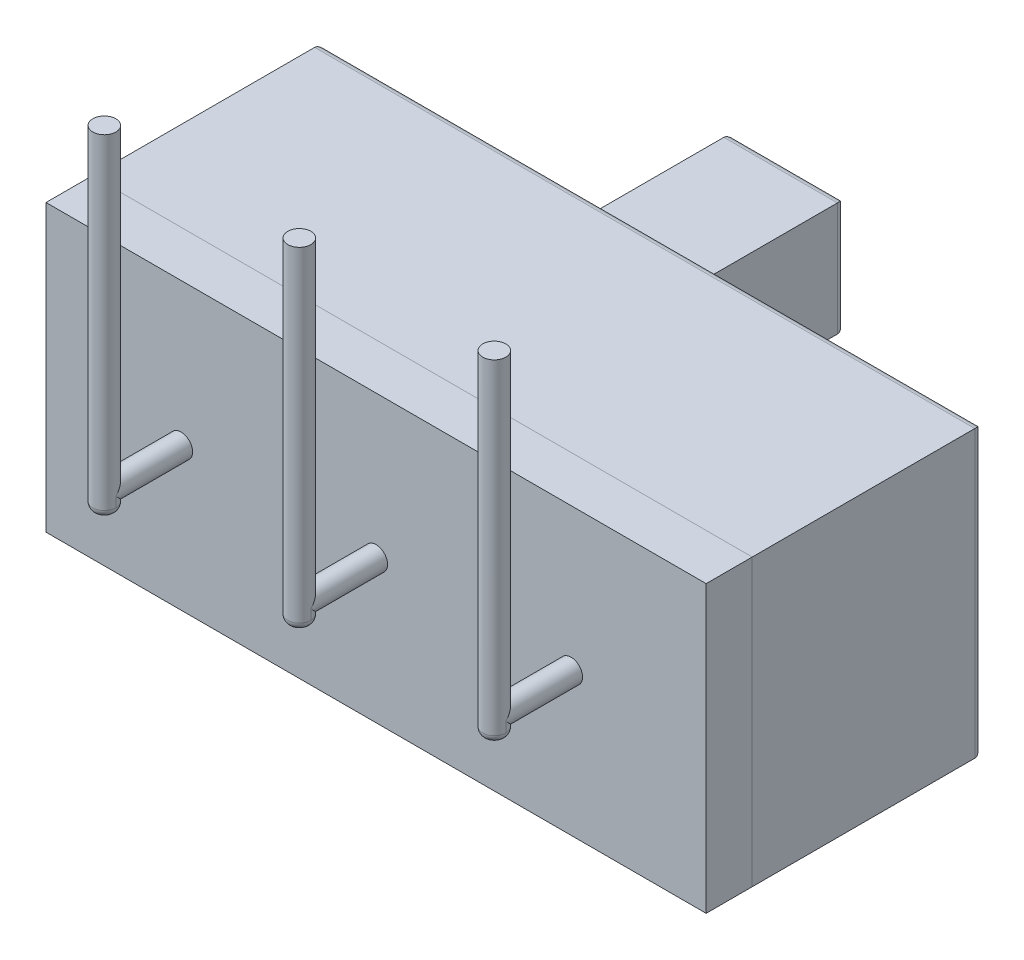
from build123d import *

# Parameters (mm, degrees)
SKETCH_1_W           = 8.6
SKETCH_1_H           = 3.72
EXTRUDE_1_DEPTH      = 3
SKETCH_2_W           = 8.6
SKETCH_2_H           = 3.72
EXTRUDE_2_DEPTH      = 0.6
SKETCH_3_W           = 3.5
SKETCH_3_H           = 1.5
CUT_EXTRUDE_1_DEPTH  = 0.1
SKETCH_4_W           = 1.48
SKETCH_4_H           = 1.48
EXTRUDE_3_DEPTH      = 2.87
FILLET_1_R           = 0.1
FILLET_2_R           = 0.1
SKETCH_5_R           = 0.15
EXTRUDE_4_DEPTH      = 1
EXTRUDE_4_2_DEPTH    = 1
EXTRUDE_4_3_DEPTH    = 1
SKETCH_6_R           = 0.15
EXTRUDE_5_DEPTH      = 0.24
EXTRUDE_5_DEPTH_BACK = 4.1
FILLET_3_R           = 0.1
FILLET_4_R           = 0.1
FILLET_5_R           = 0.1


with BuildPart() as part:
    # Эскиз1 → Бобышка-Вытянуть1 (new body)
    with BuildSketch(Plane.XY):
        Rectangle(SKETCH_1_W, SKETCH_1_H)
    extrude(amount=EXTRUDE_1_DEPTH)

    # Эскиз3 → Вырез-Вытянуть1 (cut)
    with BuildSketch(Plane(origin=(0, 0, 0), x_dir=(-1, 0, 0), z_dir=(0, 0, -1))):
        Rectangle(SKETCH_3_W, SKETCH_3_H)
    extrude(amount=-CUT_EXTRUDE_1_DEPTH, mode=Mode.SUBTRACT)

    # Эскиз4 → Бобышка-Вытянуть3 (add)
    with BuildSketch(Plane(origin=(0, 0, 0.1), x_dir=(-1, 0, 0), z_dir=(0, 0, -1))):
        with Locations((1, 0)):
            Rectangle(SKETCH_4_W, SKETCH_4_H)
    extrude(amount=EXTRUDE_3_DEPTH)

    # Скругление1
    fillet_1_edges = [part.edges().sort_by_distance(p)[0] for p in [
        (-1.74, 0, -2.77),
        (-1, 0.74, -2.77),
        (-0.26, 0, -2.77),
        (-1, -0.74, -2.77),
    ]]
    fillet(fillet_1_edges, radius=FILLET_1_R)

    # Скругление2
    fillet_2_edges = [part.edges().sort_by_distance(p)[0] for p in [
        (0, -1.86, 0),
        (-4.3, 0, 0),
        (0, 1.86, 0),
        (4.3, 0, 0),
    ]]
    fillet(fillet_2_edges, radius=FILLET_2_R)


with BuildPart() as body_2:
    # Эскиз2 → Бобышка-Вытянуть2 (new body)
    with BuildSketch(Plane.XY.offset(3)):
        Rectangle(SKETCH_2_W, SKETCH_2_H)
    extrude(amount=EXTRUDE_2_DEPTH)


with BuildPart() as body_3:
    # Эскиз5 → Бобышка-Вытянуть4 (new body)
    with BuildSketch(Plane.XY.offset(3.6)):
        Circle(SKETCH_5_R)
    extrude(amount=EXTRUDE_4_DEPTH)



with BuildPart() as body_4:
    # Эскиз5 → Extrude 4 2 (new body)
    with BuildSketch(Plane.XY.offset(3.6)):
        with Locations((-2.54, 0)):
            Circle(SKETCH_5_R)
    extrude(amount=EXTRUDE_4_2_DEPTH)


with BuildPart() as body_5:
    # Эскиз5 → Extrude 4 3 (new body)
    with BuildSketch(Plane.XY.offset(3.6)):
        with Locations((2.54, 0)):
            Circle(SKETCH_5_R)
    extrude(amount=EXTRUDE_4_3_DEPTH)


with BuildPart() as body_3_1:
    add(body_3.part)

    add(body_4.part)  # Бобышка-Вытянуть5 merges body 4

    add(body_5.part)  # Бобышка-Вытянуть5 merges body 5
    # Эскиз6 → Бобышка-Вытянуть5 (add, two sides)
    with BuildSketch(Plane(origin=(0, 0.01, 0), x_dir=(-1, 0, 0), z_dir=(0, -1, 0))) as extrude_5_sk:
        with Locations(Location((-2.54, -4.6, 0), (0, 0, 90))):
            Circle(SKETCH_6_R)
        with Locations(Location((0, -4.6, 0), (0, 0, 90))):
            Circle(SKETCH_6_R)
        with Locations(Location((2.54, -4.6, 0), (0, 0, 90))):
            Circle(SKETCH_6_R)
    extrude(amount=EXTRUDE_5_DEPTH)
    extrude(extrude_5_sk.sketch, amount=-EXTRUDE_5_DEPTH_BACK)

    # Скругление3
    fillet_3_edges = [body_3_1.edges().sort_by_distance(p)[0] for p in [
        (2.54, -0.23, 4.75),
    ]]
    fillet(fillet_3_edges, radius=FILLET_3_R)

    # Скругление4
    fillet_4_edges = [body_3_1.edges().sort_by_distance(p)[0] for p in [
        (0, -0.23, 4.75),
    ]]
    fillet(fillet_4_edges, radius=FILLET_4_R)

    # Скругление5
    fillet_5_edges = [body_3_1.edges().sort_by_distance(p)[0] for p in [
        (-2.54, -0.23, 4.75),
    ]]
    fillet(fillet_5_edges, radius=FILLET_5_R)


solid = Compound([part.part, body_2.part, body_3_1.part])
